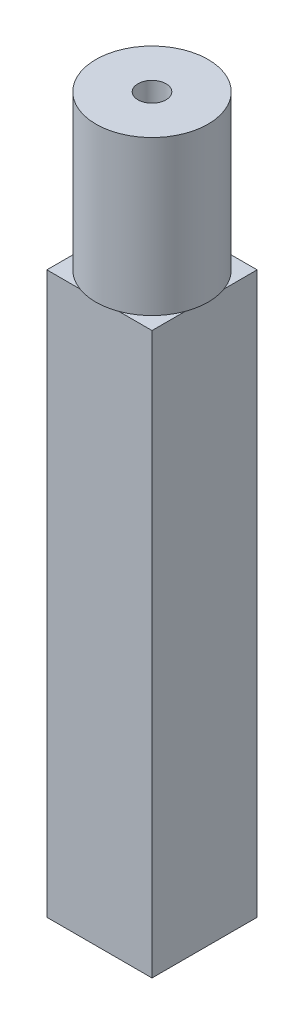
from build123d import *

# Parameters (mm, degrees)
SKETCH_1_R          = 8
EXTRUDE_1_DEPTH     = 22
SKETCH_2_W          = 15
SKETCH_2_H          = 15
EXTRUDE_2_DEPTH     = 80
SKETCH_3_R          = 2
CUT_EXTRUDE_1_DEPTH = 11


with BuildPart() as part:
    # 草图1 → 凸台-拉伸1 (new body)
    with BuildSketch(Plane(origin=(0, 0, 0), x_dir=(1, 0, 0), z_dir=(0, 1, 0))):
        Circle(SKETCH_1_R)
    extrude(amount=EXTRUDE_1_DEPTH)

    # 草图2 → 凸台-拉伸2 (add)
    with BuildSketch(Plane.XZ):
        Rectangle(SKETCH_2_W, SKETCH_2_H)
    extrude(amount=EXTRUDE_2_DEPTH)

    # 草图3 → 切除-拉伸1 (cut)
    with BuildSketch(Plane(origin=(0, 22, 0), x_dir=(1, 0, 0), z_dir=(0, 1, 0))):
        Circle(SKETCH_3_R)
    extrude(amount=-CUT_EXTRUDE_1_DEPTH, mode=Mode.SUBTRACT)


solid = part.part
